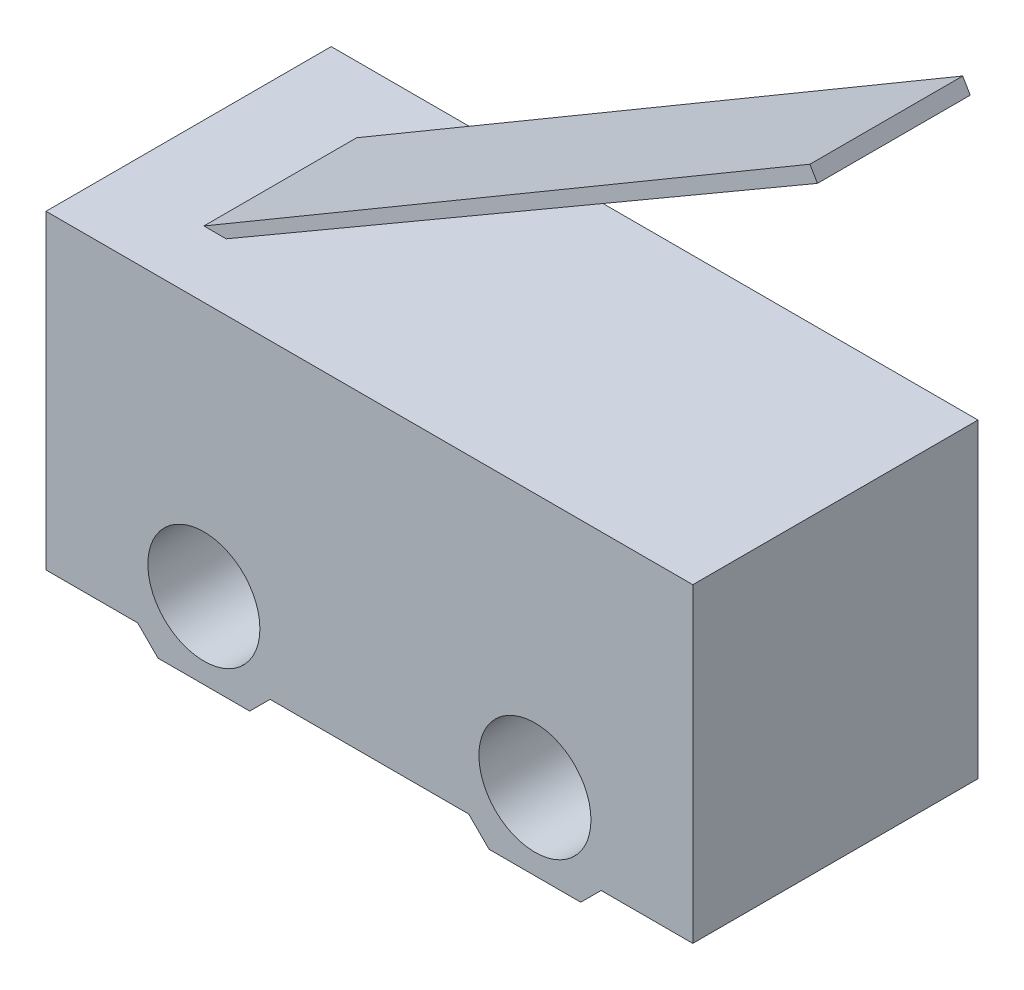
from build123d import *

# Parameters (mm, degrees)
SKETCH_1_R      = 1.1
EXTRUDE_1_DEPTH = 5.6
EXTRUDE_2_DEPTH = 1.5


with BuildPart() as part:
    # 草图1 → 凸台-拉伸1 (new body)
    with BuildSketch(Plane.XY):
        Polygon((1.8, 0.4), (2.2, 0), (4, 0), (4.4, 0.4), (8.3, 0.4), (8.7, 0), (10.5, 0), (10.9, 0.4), (12.7, 0.4), (12.7, 6.5), (2.517906402, 6.5), (2, 6.5), (0, 6.5), (0, 0.4), align=None)
        with Locations((3.1, 1.5)):
            Circle(SKETCH_1_R, mode=Mode.SUBTRACT)
        with Locations((9.6, 1.5)):
            Circle(SKETCH_1_R, mode=Mode.SUBTRACT)
    extrude(amount=EXTRUDE_1_DEPTH)

    # 草图3 → 凸台-拉伸2 (add, symmetric)
    with BuildSketch(Plane.XY.offset(2.8)):
        Polygon((1.8, 6.5), (13.7, 13.5), (13.84831969, 13.247856527), (2.238287657, 6.5), align=None)
    extrude(amount=EXTRUDE_2_DEPTH, both=True)


solid = part.part
